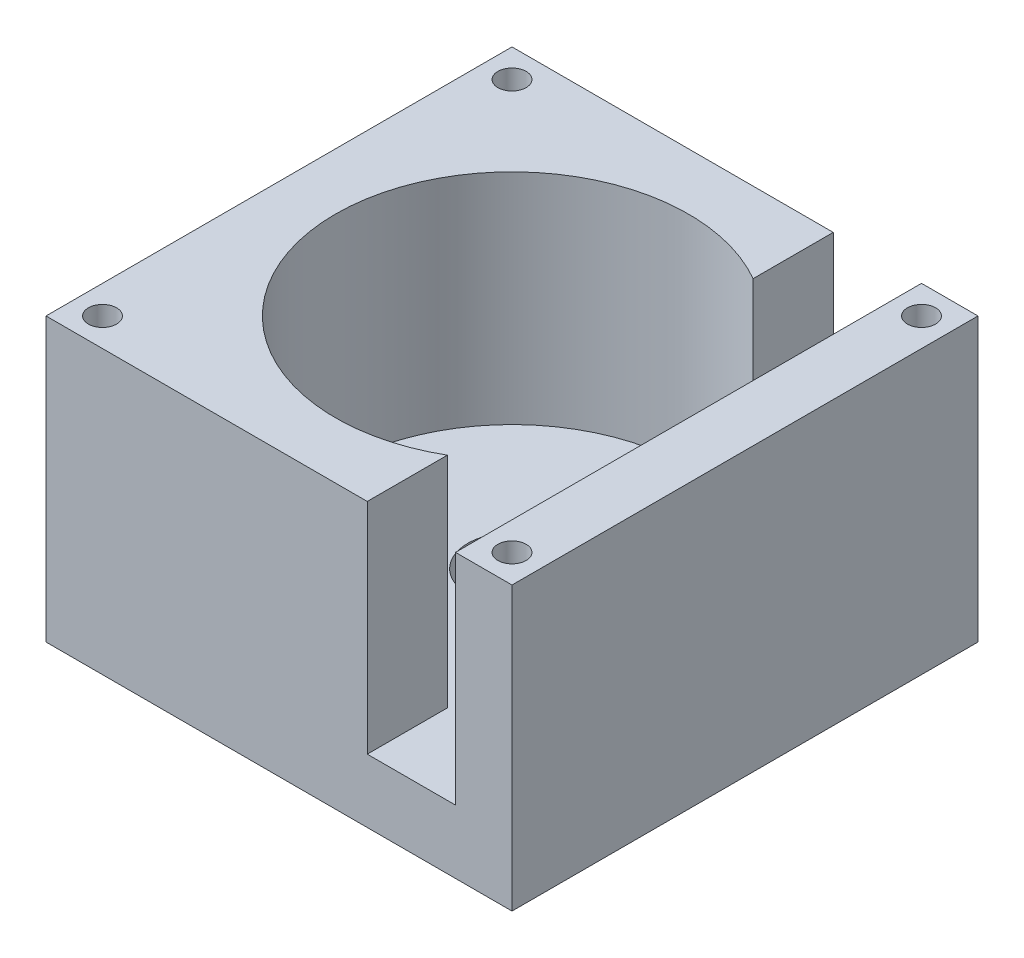
from build123d import *

# Parameters (mm, degrees)
SKETCH1_W               = 66
SKETCH1_H               = 66
BOSS_EXTRUDE1_DEPTH     = 40
SKETCH2_R               = 25
CUT_EXTRUDE1_DEPTH      = 31
SKETCH3_R               = 6.25
CUT_EXTRUDE2_DEPTH      = 7
SKETCH4_W               = 12.5
SKETCH4_H               = 31
CUT_EXTRUDE3_DEPTH      = 1
CUT_EXTRUDE3_DEPTH_BACK = 67
SKETCH5_R               = 2
CUT_EXTRUDE4_DEPTH      = 10


with BuildPart() as part:
    # Sketch1 → Boss-Extrude1 (new body)
    with BuildSketch(Plane(origin=(0, 0, 0), x_dir=(1, 0, 0), z_dir=(0, 1, 0))):
        Rectangle(SKETCH1_W, SKETCH1_H)
    extrude(amount=BOSS_EXTRUDE1_DEPTH)

    # Sketch2 → Cut-Extrude1 (cut)
    with BuildSketch(Plane(origin=(0, 40, 0), x_dir=(1, 0, 0), z_dir=(0, 1, 0))):
        Circle(SKETCH2_R)
    extrude(amount=-CUT_EXTRUDE1_DEPTH, mode=Mode.SUBTRACT)

    # Sketch3 → Cut-Extrude2 (cut)
    with BuildSketch(Plane(origin=(0, 9, 0), x_dir=(1, 0, 0), z_dir=(0, 1, 0))):
        Circle(SKETCH3_R)
    extrude(amount=-CUT_EXTRUDE2_DEPTH, mode=Mode.SUBTRACT)

    # Sketch4 → Cut-Extrude3 (cut, two sides)
    with BuildSketch(Plane.XY.offset(33)) as cut_extrude3_sk:
        with Locations((18.75, 24.5)):
            Rectangle(SKETCH4_W, SKETCH4_H)
    extrude(amount=CUT_EXTRUDE3_DEPTH, mode=Mode.SUBTRACT)
    extrude(cut_extrude3_sk.sketch, amount=-CUT_EXTRUDE3_DEPTH_BACK, mode=Mode.SUBTRACT)

    # Sketch5 → Cut-Extrude4 (cut)
    with BuildSketch(Plane(origin=(0, 40, 0), x_dir=(1, 0, 0), z_dir=(0, 1, 0))):
        with Locations((-29, -29)):
            Circle(SKETCH5_R)
        with Locations((-29, 29)):
            Circle(SKETCH5_R)
        with Locations((29, 29)):
            Circle(SKETCH5_R)
        with Locations((29, -29)):
            Circle(SKETCH5_R)
    extrude(amount=-CUT_EXTRUDE4_DEPTH, mode=Mode.SUBTRACT)


solid = part.part
